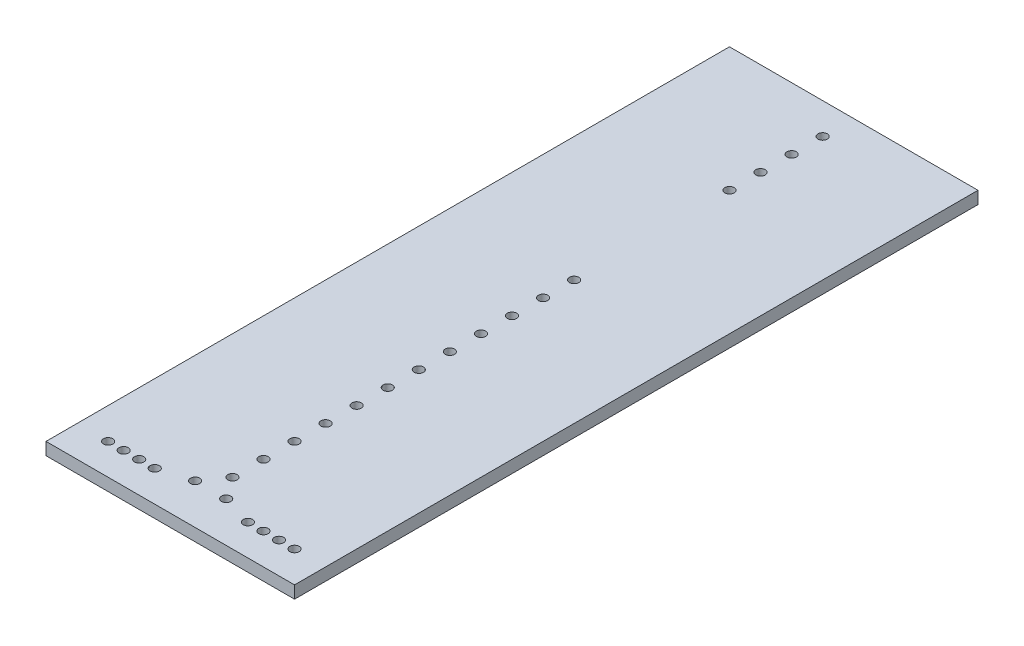
from build123d import *

# Parameters (mm, degrees)
SKETCH2_W           = 80
SKETCH2_H           = 220
MAIN_PLATE_DEPTH    = 4
SKETCH3_R           = 1.5
ELBOW_HOLES_DEPTH   = 5
SKETCH4_R           = 1.5
PIN_HOLES_DEPTH     = 5
SKETCH5_R           = 1.5
STOPPER_HOLES_DEPTH = 5
SKETCH6_R           = 1.5
SPOOL_HOLES_DEPTH   = 5


with BuildPart() as part:
    # Sketch2 → main_plate (new body)
    with BuildSketch(Plane(origin=(0, 0, 0), x_dir=(1, 0, 0), z_dir=(0, 1, 0))):
        Rectangle(SKETCH2_W, SKETCH2_H)
    extrude(amount=MAIN_PLATE_DEPTH)

    # Sketch3 → elbow_holes (cut, through all)
    with BuildSketch(Plane(origin=(0, 4, 0), x_dir=(1, 0, 0), z_dir=(0, 1, 0))):
        with Locations((30, -100)):
            Circle(SKETCH3_R)
        with Locations((25, -100)):
            Circle(SKETCH3_R)
        with Locations((20, -100)):
            Circle(SKETCH3_R)
        with Locations((15, -100)):
            Circle(SKETCH3_R)
    elbow_holes = extrude(amount=-ELBOW_HOLES_DEPTH, mode=Mode.SUBTRACT)

    # elbow_mirror: elbow_holes across plane
    add(elbow_holes.mirror(Plane(origin=(0, 0, 0), x_dir=(0, 0, 1), z_dir=(1, 0, 0))), mode=Mode.SUBTRACT)

    # Sketch4 → pin_holes (cut, through all)
    with BuildSketch(Plane(origin=(0, 4, 0), x_dir=(1, 0, 0), z_dir=(0, 1, 0))):
        with Locations((0, -90)):
            Circle(SKETCH4_R)
        with Locations((0, -80)):
            Circle(SKETCH4_R)
        with Locations((0, -70)):
            Circle(SKETCH4_R)
        with Locations((0, -60)):
            Circle(SKETCH4_R)
        with Locations((0, -50)):
            Circle(SKETCH4_R)
        with Locations((0, -40)):
            Circle(SKETCH4_R)
        with Locations((0, -30)):
            Circle(SKETCH4_R)
        with Locations((0, -20)):
            Circle(SKETCH4_R)
        with Locations((0, -10)):
            Circle(SKETCH4_R)
        Circle(SKETCH4_R)
        with Locations((0, 10)):
            Circle(SKETCH4_R)
        with Locations((0, 20)):
            Circle(SKETCH4_R)
    extrude(amount=-PIN_HOLES_DEPTH, mode=Mode.SUBTRACT)

    # Sketch5 → stopper_holes (cut, through all)
    with BuildSketch(Plane(origin=(0, 4, 0), x_dir=(1, 0, 0), z_dir=(0, 1, 0))):
        with Locations((5, -97)):
            Circle(SKETCH5_R)
    stopper_holes = extrude(amount=-STOPPER_HOLES_DEPTH, mode=Mode.SUBTRACT)

    # stopper_mirror: stopper_holes across plane
    add(stopper_holes.mirror(Plane(origin=(0, 0, 0), x_dir=(0, 0, 1), z_dir=(1, 0, 0))), mode=Mode.SUBTRACT)

    # Sketch6 → spool_holes (cut, through all)
    with BuildSketch(Plane(origin=(0, 4, 0), x_dir=(1, 0, 0), z_dir=(0, 1, 0))):
        with Locations((0, 70)):
            Circle(SKETCH6_R)
        with Locations((0, 80)):
            Circle(SKETCH6_R)
        with Locations((0, 90)):
            Circle(SKETCH6_R)
        with Locations((0, 100)):
            Circle(SKETCH6_R)
    extrude(amount=-SPOOL_HOLES_DEPTH, mode=Mode.SUBTRACT)


solid = part.part
